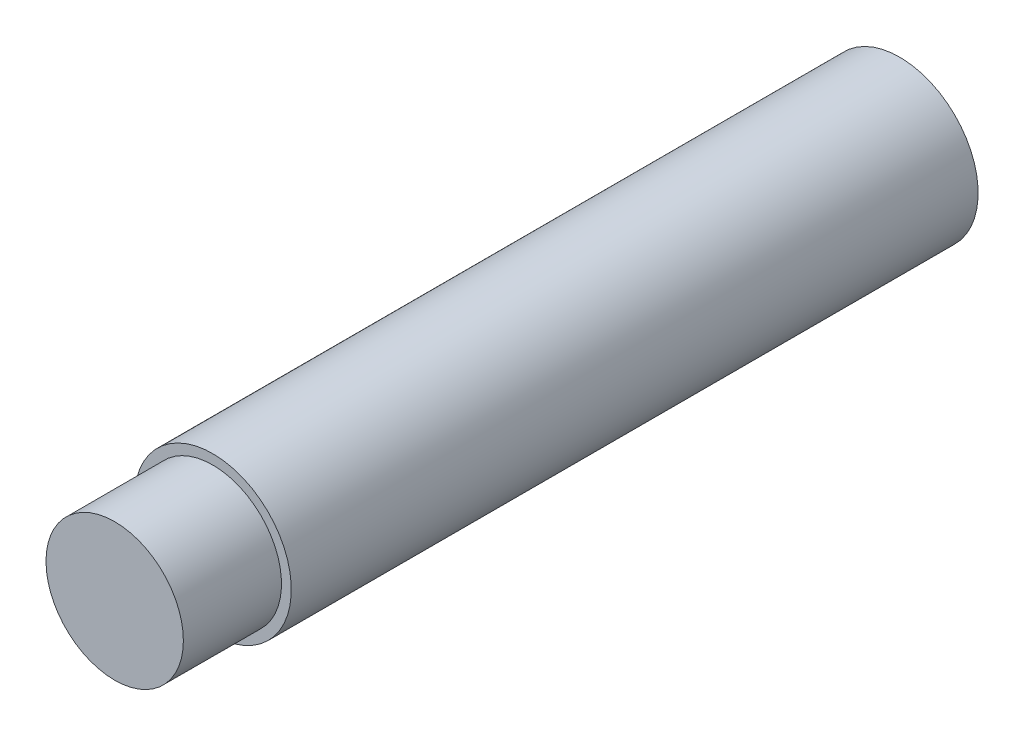
from build123d import *

# Parameters (mm, degrees)
SKETCH_1_R      = 5.25
EXTRUDE_1_DEPTH = 7.5
SKETCH_2_R      = 6
EXTRUDE_2_DEPTH = 42.5
SKETCH_3_R      = 6
EXTRUDE_3_DEPTH = 10


with BuildPart() as part:
    # 草图1 → 凸台-拉伸1 (new body)
    with BuildSketch(Plane.XY):
        Circle(SKETCH_1_R)
    extrude(amount=EXTRUDE_1_DEPTH)

    # 草图2 → 凸台-拉伸2 (add)
    with BuildSketch(Plane(origin=(0, 0, 0), x_dir=(-1, 0, 0), z_dir=(0, 0, -1))):
        Circle(SKETCH_2_R)
    extrude(amount=EXTRUDE_2_DEPTH)

    # 草图3 → 凸台-拉伸3 (add)
    with BuildSketch(Plane(origin=(0, 0, -42.5), x_dir=(-1, 0, 0), z_dir=(0, 0, -1))):
        Circle(SKETCH_3_R)
    extrude(amount=EXTRUDE_3_DEPTH)


solid = part.part
